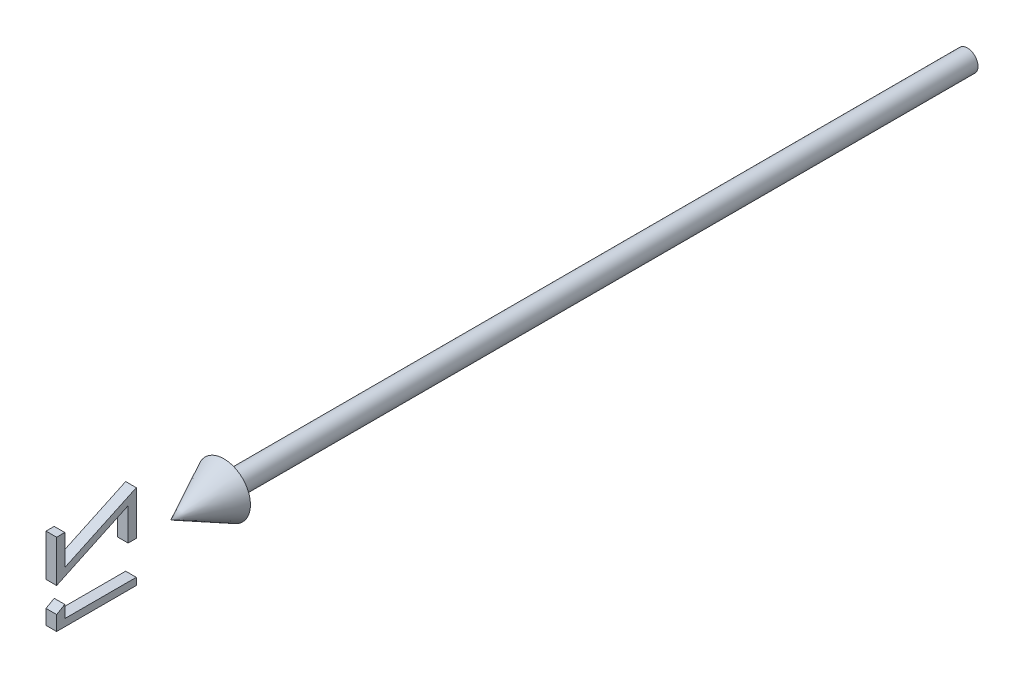
from build123d import *

# Parameters (mm, degrees)
BOSS_EXTRUDE1_DEPTH        = 1
BOSS_EXTRUDE1_DEPTH_BACK   = 1
BOSS_EXTRUDE1_2_DEPTH      = 1
BOSS_EXTRUDE1_2_DEPTH_BACK = 1


with BuildPart() as part:
    # Sketch2 → Revolve1 (revolve)
    with BuildSketch(Plane(origin=(0, 0, 0), x_dir=(1, 0, 0), z_dir=(0, 1, 0))):
        Polygon((0, -150), (5, -140), (2, -140), (2, 0), (0, 0), align=None)
    revolve(axis=Axis((0, 0, -41.949952025), (0, 0, 1)))


with BuildPart() as body_2:
    # Sketch3 → Boss-Extrude1 (new, two sides: drawn at the far end of the back side and taken through both)
    with BuildSketch(Plane(origin=(0, 0, 0), x_dir=(0, -1, 0), z_dir=(1, 0, 0)).offset(-BOSS_EXTRUDE1_DEPTH_BACK)):
        Polygon((-8.958586521, -170.961538462), (-8.958586521, -172.5), (-1.073971137, -172.5), (-7.366038444, -159.038461538), (-1.266278829, -159.038461538), (-1.266278829, -157.5), (-9.535509598, -157.5), (-3.243442291, -170.961538462), align=None)
    extrude(amount=BOSS_EXTRUDE1_DEPTH + BOSS_EXTRUDE1_DEPTH_BACK)


with BuildPart() as body_3:
    # Sketch3 → Boss-Extrude1 2 (new, two sides: drawn at the far end of the back side and taken through both)
    with BuildSketch(Plane(origin=(0, 0, 0), x_dir=(0, -1, 0), z_dir=(1, 0, 0)).offset(-BOSS_EXTRUDE1_2_DEPTH_BACK)):
        Polygon((3.652591363, -172.5), (6.426028863, -172.5), (6.426028863, -157.5), (5.079875017, -157.5), (5.079875017, -170.961538462), (2.772182709, -170.961538462), align=None)
    extrude(amount=BOSS_EXTRUDE1_2_DEPTH + BOSS_EXTRUDE1_2_DEPTH_BACK)


solid = Compound([part.part, body_2.part, body_3.part])
